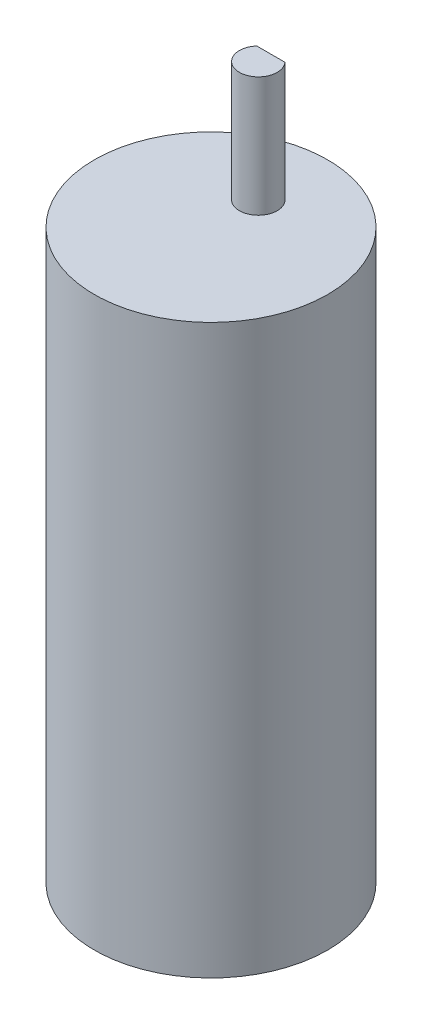
from build123d import *

# Parameters (mm, degrees)
ESBO_O1_W                = 18.5
ESBO_O1_H                = 90
RESSALTO_EXTRUS_O1_DEPTH = 19


with BuildPart() as part:
    # Esboço1 → Revolução1 (revolve)
    with BuildSketch(Plane.XY):
        with Locations((9.25, -45)):
            Rectangle(ESBO_O1_W, ESBO_O1_H)
    revolve(axis=Axis((0, -90, 0), (0, 1, 0)))

    # Esboço2 → Ressalto-extrusão1 (add)
    with BuildSketch(Plane(origin=(0, 0, 0), x_dir=(1, 0, 0), z_dir=(0, 1, 0))):
        with BuildLine():
            Line((-2.236067977, 9.5), (2.236067977, 9.5))
            ThreePointArc((2.236067977, 9.5), (0, 4.5), (-2.236067977, 9.5))
        make_face()
    extrude(amount=RESSALTO_EXTRUS_O1_DEPTH)


solid = part.part
